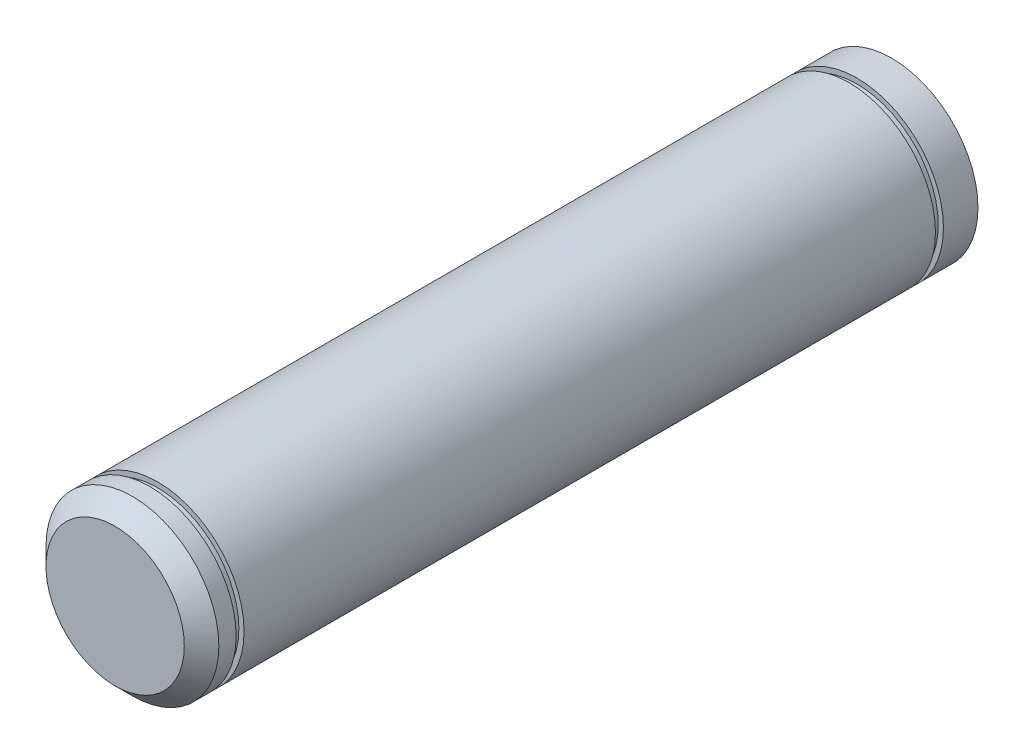
from build123d import *

# Parameters (mm, degrees)
SKETCH3_R           = 12.7
BOSS_EXTRUDE1_DEPTH = 304.8
CHAMFER1_SIZE       = 2.54
CUT_EXTRUDE1_START  = -114.1
SKETCH4_R           = 12.7
CUT_EXTRUDE1_DEPTH  = 496.5
CUT_EXTRUDE2_START  = -5.08
SKETCH5_R           = 12.7
SKETCH5_R_2         = 11.938
CUT_EXTRUDE2_DEPTH  = 1.1684


with BuildPart() as part:
    # Sketch3 → Boss-Extrude1 (new body, symmetric)
    with BuildSketch(Plane.XY):
        Circle(SKETCH3_R)
    extrude(amount=BOSS_EXTRUDE1_DEPTH, both=True)

    # Chamfer1
    chamfer1_edges = [part.edges().sort_by_distance(p)[0] for p in [
        (-12.7, 0, -304.8),
        (-12.7, 0, 304.8),
    ]]
    chamfer(chamfer1_edges, length=CHAMFER1_SIZE)

    # Sketch4 → Cut-Extrude1 (cut, through all)
    with BuildSketch(Plane.XY.offset(304.8).offset(CUT_EXTRUDE1_START)):
        Circle(SKETCH4_R)
    extrude(amount=-CUT_EXTRUDE1_DEPTH, mode=Mode.SUBTRACT)

    # Sketch5 → Cut-Extrude2 (cut)
    with BuildSketch(Plane.XY.offset(304.8).offset(CUT_EXTRUDE2_START)):
        Circle(SKETCH5_R)
        Circle(SKETCH5_R_2, mode=Mode.SUBTRACT)
    cut_extrude2 = extrude(amount=-CUT_EXTRUDE2_DEPTH, mode=Mode.SUBTRACT)

    # Mirror3: Cut-Extrude2 across plane
    add(cut_extrude2.mirror(Plane.XY.offset(247.75)), mode=Mode.SUBTRACT)


solid = part.part
